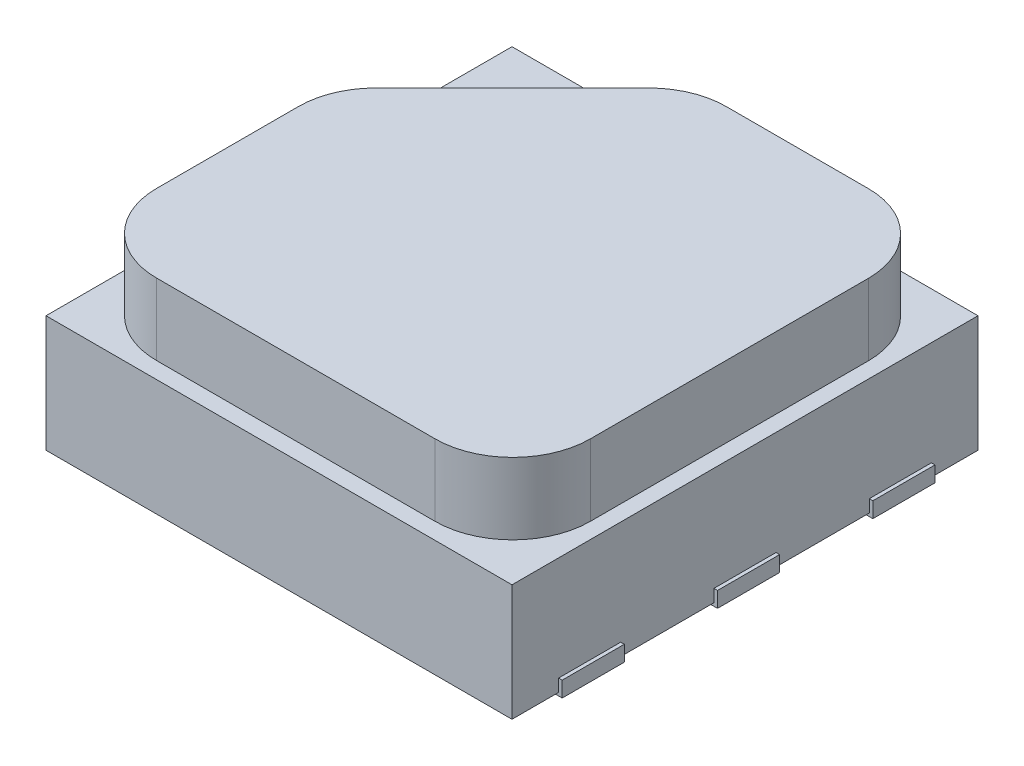
from build123d import *

# Parameters (mm, degrees)
SKETCH1_W           = 3
SKETCH1_H           = 3
BOSS_EXTRUDE1_DEPTH = 0.75
SKETCH2_W           = 2.792510514
SKETCH2_H           = 2.789908115
BOSS_EXTRUDE2_DEPTH = 0.46
FILLET1_R           = 0.5
CHAMFER1_SIZE       = 1.17
FILLET2_R           = 0.5
BOSS_EXTRUDE3_START = 0.02
BOSS_EXTRUDE3_DEPTH = 0.1


with BuildPart() as part:
    # Sketch1 → Boss-Extrude1 (new body)
    with BuildSketch(Plane(origin=(0, 0, 0), x_dir=(1, 0, 0), z_dir=(0, 1, 0))):
        with Locations((1.5, 1.5)):
            Rectangle(SKETCH1_W, SKETCH1_H)
    extrude(amount=BOSS_EXTRUDE1_DEPTH)

    # Sketch2 → Boss-Extrude2 (add)
    with BuildSketch(Plane(origin=(0, 0.75, 0), x_dir=(1, 0, 0), z_dir=(0, 1, 0))):
        with Locations((1.502321274, 1.501020074)):
            Rectangle(SKETCH2_W, SKETCH2_H)
    extrude(amount=BOSS_EXTRUDE2_DEPTH)

    # Fillet1
    fillet1_edges = [part.edges().sort_by_distance(p)[0] for p in [
        (2.898576531, 0.98, -0.106066017),
        (2.898576531, 0.98, -2.895974132),
        (0.106066017, 0.98, -0.106066017),
    ]]
    fillet(fillet1_edges, radius=FILLET1_R)

    # Chamfer1
    chamfer1_edges = [part.edges().sort_by_distance(p)[0] for p in [
        (0.106066017, 0.98, -2.895974132),
    ]]
    chamfer(chamfer1_edges, length=CHAMFER1_SIZE)

    # Fillet2
    fillet2_edges = [part.edges().sort_by_distance(p)[0] for p in [
        (0.106066017, 0.98, -1.725974132),
        (1.276066017, 0.98, -2.895974132),
    ]]
    fillet(fillet2_edges, radius=FILLET2_R)

    # Sketch4 → Boss-Extrude3 (add)
    with BuildSketch(Plane(origin=(0, 0, 0), x_dir=(-1, 0, 0), z_dir=(0, -1, 0)).offset(BOSS_EXTRUDE3_START)):
        with BuildLine():
            Line((-0.2, 0.3), (0, 0.3))
            Line((0, 0.3), (0.02310672, 0.3))
            Line((0.02310672, 0.3), (0.02310672, 0.7))
            Line((0.02310672, 0.7), (0, 0.7))
            Line((0, 0.7), (-0.2, 0.7))
            ThreePointArc((-0.2, 0.7), (-0.4, 0.5), (-0.2, 0.3))
        make_face()
        with BuildLine():
            Line((-0.2, 1.3), (0, 1.3))
            Line((0, 1.3), (0.02310672, 1.3))
            Line((0.02310672, 1.3), (0.02310672, 1.7))
            Line((0.02310672, 1.7), (0, 1.7))
            Line((0, 1.7), (-0.2, 1.7))
            ThreePointArc((-0.2, 1.7), (-0.4, 1.5), (-0.2, 1.3))
        make_face()
        with BuildLine():
            Line((-0.2, 2.7), (0, 2.7))
            Line((0, 2.7), (0.02310672, 2.7))
            Line((0.02310672, 2.7), (0.02310672, 2.300077799))
            Line((0.02310672, 2.300077799), (0, 2.300077799))
            Line((0, 2.300077799), (-0.2, 2.300077799))
            ThreePointArc((-0.2, 2.300077799), (-0.4, 2.500038899), (-0.2, 2.7))
        make_face()
    boss_extrude3 = extrude(amount=-BOSS_EXTRUDE3_DEPTH)

    # Mirror1: Boss-Extrude3 across plane
    add(boss_extrude3.mirror(Plane(origin=(1.5, 0, 0), x_dir=(0, 0, 1), z_dir=(1, 0, 0))))


solid = part.part
